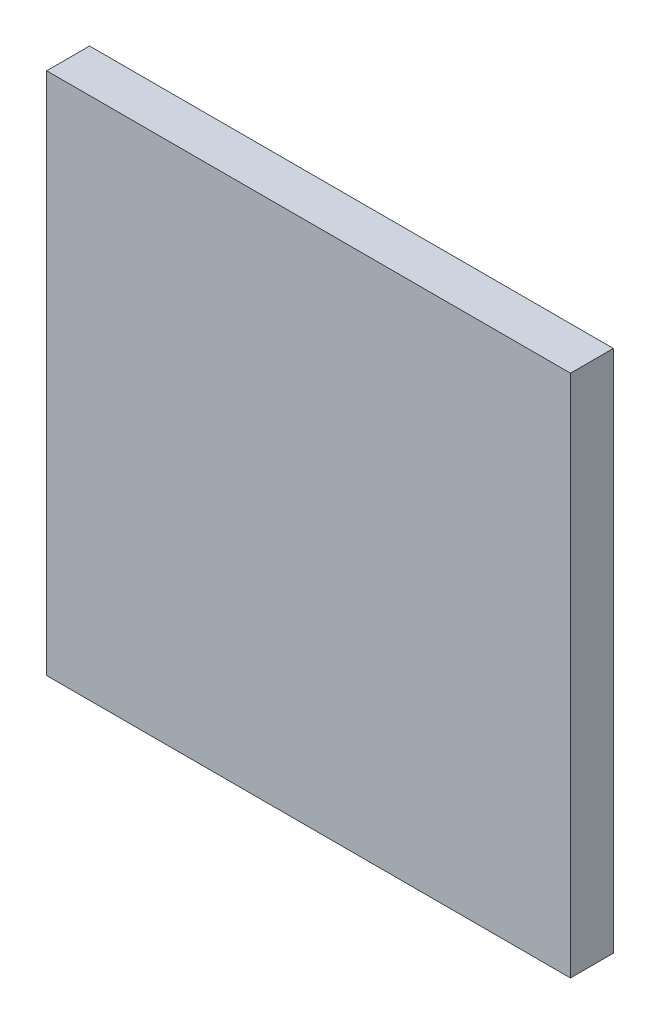
from build123d import *

# Parameters (mm, degrees)
SKETCH1_W           = 56.2
SKETCH1_H           = 56.2
BOSS_EXTRUDE1_DEPTH = 4.6


with BuildPart() as part:
    # Sketch1 → Boss-Extrude1 (new body)
    with BuildSketch(Plane.XY):
        Rectangle(SKETCH1_W, SKETCH1_H)
    extrude(amount=BOSS_EXTRUDE1_DEPTH)


solid = part.part
